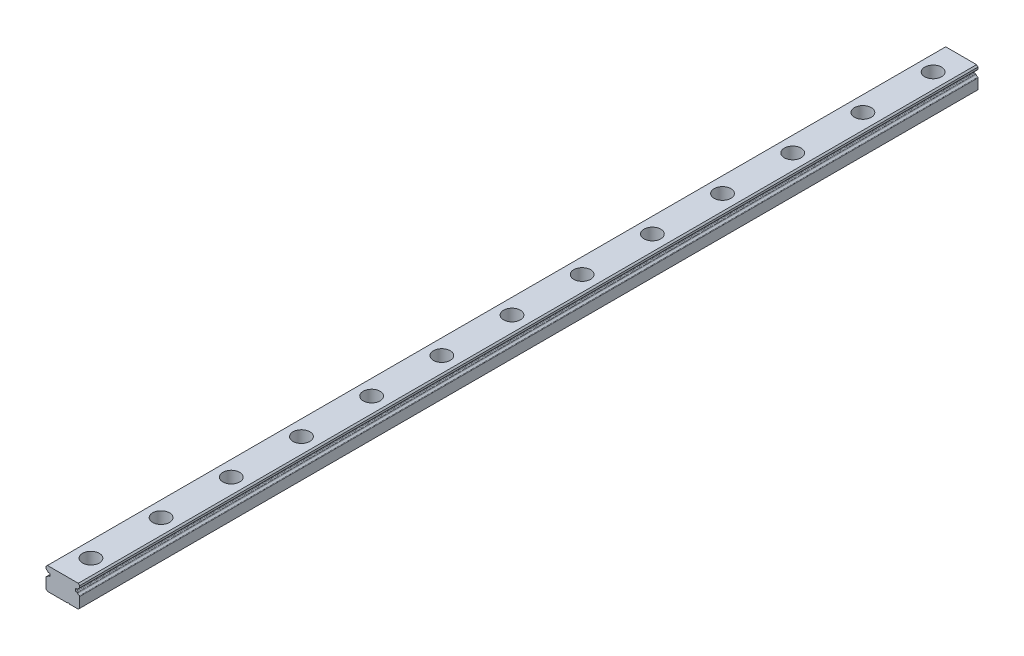
from build123d import *

# Parameters (mm, degrees)
BOSS_EXTRUDE1_START = 160
BOSS_EXTRUDE1_DEPTH = 320
LPATTERN1_COUNT     = 13
LPATTERN1_PITCH     = 25


with BuildPart() as part:
    # Sketch3 → Boss-Extrude1 (new body)
    with BuildSketch(Plane.XY.offset(BOSS_EXTRUDE1_START)):
        with BuildLine():
            Line((-6, 0.142120421), (-6, -3.5))
            Line((-6, -3.5), (-5.5, -4))
            Line((-5.5, -4), (1.6, -4))
            ThreePointArc((1.6, -4), (2, -3.8), (2.4, -4.000000001))
            Line((2.4, -4.000000001), (5.5, -4.000000001))
            Line((5.5, -4.000000001), (6, -3.500000001))
            Line((6, -3.500000001), (6, 0.14212042))
            ThreePointArc((6, 0.14212042), (5.9576137, 0.281391924), (5.844827586, 0.373437797))
            ThreePointArc((5.844827586, 0.373437797), (5.51524529, 0.575928598), (5.267205011, 0.87275015))
            ThreePointArc((5.267205011, 0.87275015), (5.185241933, 0.957014877), (5.073828324, 0.994504855))
            Line((5.073828324, 0.994504855), (4.728211064, 1.024742447))
            ThreePointArc((4.728211064, 1.024742447), (4.565680666, 1.10489357), (4.5, 1.273791122))
            Line((4.5, 1.273791122), (4.5, 1.726212879))
            ThreePointArc((4.5, 1.726212879), (4.565680666, 1.89511043), (4.728211064, 1.975261553))
            Line((4.728211064, 1.975261553), (5.09477657, 2.007331879))
            ThreePointArc((5.09477657, 2.007331879), (5.203244499, 2.042995575), (5.284541491, 2.123170322))
            ThreePointArc((5.284541491, 2.123170322), (5.527906161, 2.402385779), (5.844827586, 2.594084617))
            ThreePointArc((5.844827586, 2.594084617), (5.9576137, 2.68613049), (6, 2.825401993))
            Line((6, 2.825401993), (6, 3.5))
            Line((6, 3.5), (5.5, 4))
            Line((5.5, 4), (-5.5, 4))
            Line((-5.5, 4), (-6, 3.5))
            Line((-6, 3.5), (-6, 2.825401994))
            ThreePointArc((-6, 2.825401994), (-5.9576137, 2.68613049), (-5.844827586, 2.594084617))
            ThreePointArc((-5.844827586, 2.594084617), (-5.527906161, 2.402385779), (-5.284541491, 2.123170322))
            ThreePointArc((-5.284541491, 2.123170322), (-5.203244499, 2.042995575), (-5.09477657, 2.007331879))
            Line((-5.09477657, 2.007331879), (-4.728211064, 1.975261553))
            ThreePointArc((-4.728211064, 1.975261553), (-4.565680666, 1.89511043), (-4.5, 1.726212879))
            Line((-4.5, 1.726212879), (-4.5, 1.273791122))
            ThreePointArc((-4.5, 1.273791122), (-4.565680666, 1.10489357), (-4.728211064, 1.024742447))
            Line((-4.728211064, 1.024742447), (-5.073828324, 0.994504855))
            ThreePointArc((-5.073828324, 0.994504855), (-5.185241933, 0.957014877), (-5.267205011, 0.87275015))
            ThreePointArc((-5.267205011, 0.87275015), (-5.51524529, 0.575928598), (-5.844827586, 0.373437797))
            ThreePointArc((-5.844827586, 0.373437797), (-5.9576137, 0.281391924), (-6, 0.142120421))
        make_face()
    extrude(amount=-BOSS_EXTRUDE1_DEPTH)

    # Sketch4 → Cut-Revolve1 (revolve, cut)
    with BuildSketch(Plane.XY.offset(150)):
        Polygon((0, 4), (0, -4), (-1.75, -4), (-1.75, -0.5), (-3, -0.5), (-3, 4), align=None)
    cut_revolve1 = revolve(axis=Axis((0, 4, 150), (0, -1, 0)), mode=Mode.SUBTRACT)

    # LPattern1: Cut-Revolve1 ×13
    with Locations(*[(0, 0, -i * LPATTERN1_PITCH) for i in range(1, LPATTERN1_COUNT)]):
        add(cut_revolve1, mode=Mode.SUBTRACT)


solid = part.part
